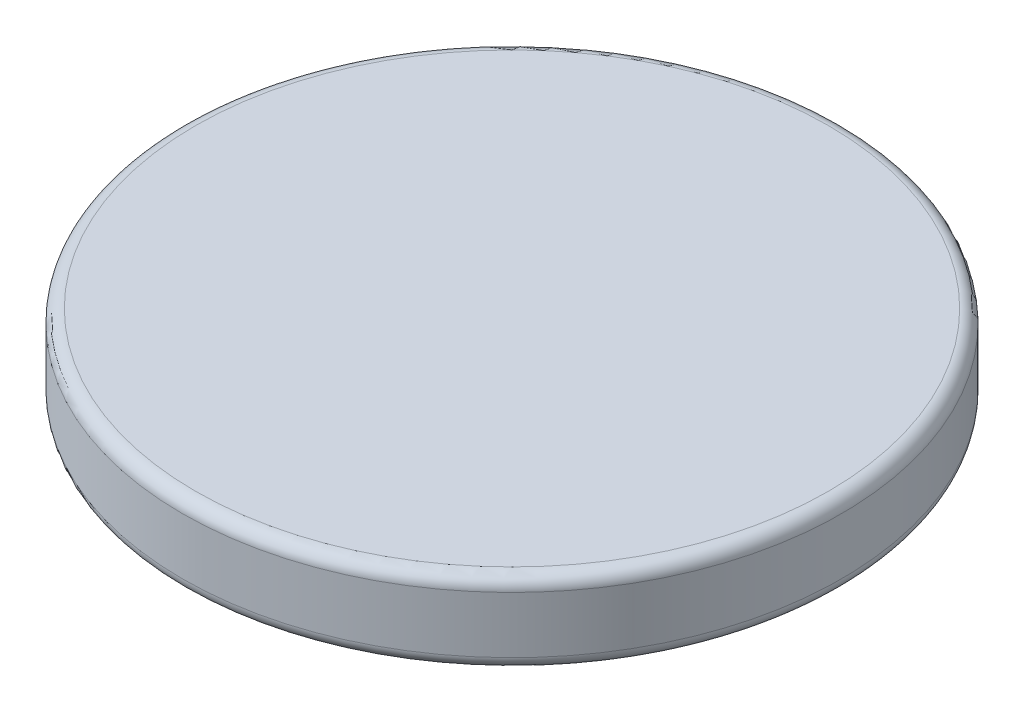
from build123d import *

# Parameters (mm, degrees)
SKETCH2_R           = 6.35
BOSS_EXTRUDE1_DEPTH = 1.5875
FILLET1_R           = 0.25


with BuildPart() as part:
    # Sketch2 → Boss-Extrude1 (new body)
    with BuildSketch(Plane(origin=(0, 0, 0), x_dir=(1, 0, 0), z_dir=(0, 1, 0))):
        Circle(SKETCH2_R)
    extrude(amount=BOSS_EXTRUDE1_DEPTH)

    # Fillet1
    fillet1_edges = [part.edges().sort_by_distance(p)[0] for p in [
        (-6.35, 0, 0),
        (-6.35, 1.5875, 0),
    ]]
    fillet(fillet1_edges, radius=FILLET1_R)


solid = part.part
